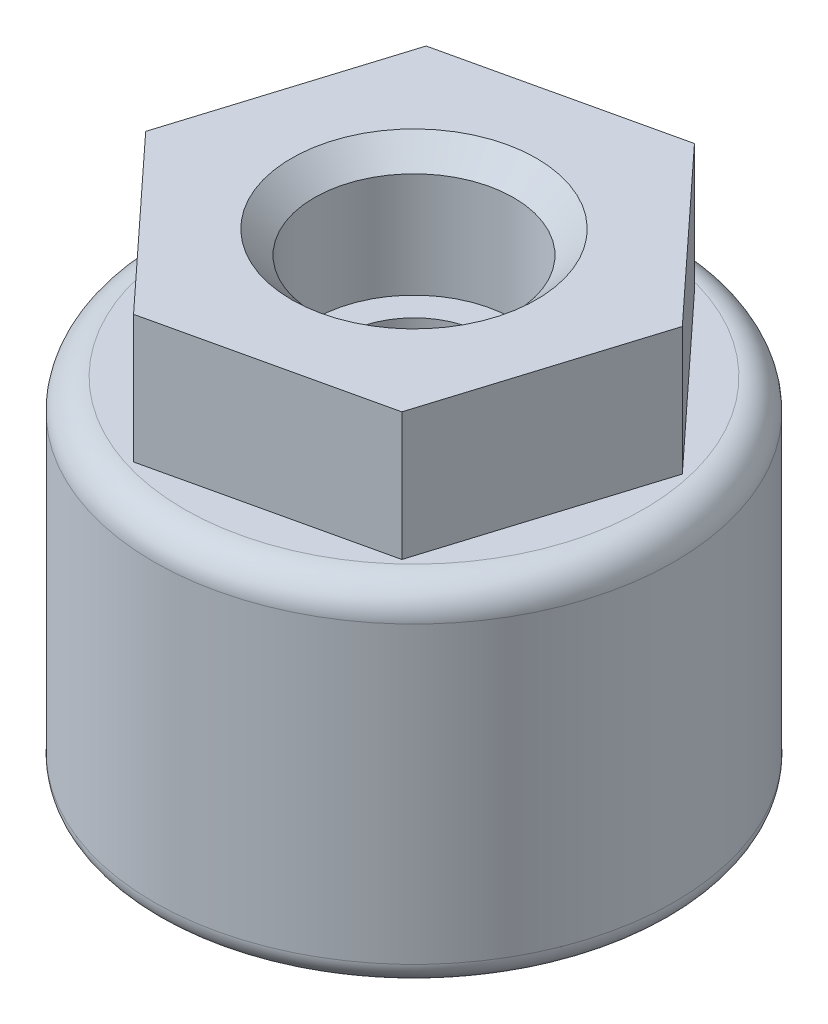
from build123d import *

# Parameters (mm, degrees)
SKETCH1_R               = 14.285
BOSS_EXTRUDE1_DEPTH     = 19.1
RADYUS1_R               = 1.67
RADYUS2_R               = 1.25
BOSS_EXTRUDE2_DEPTH     = 7.02
SKETCH4_R               = 3.95
CUT_EXTRUDE1_DEPTH      = 2
CUT_EXTRUDE1_DEPTH_BACK = 29.02
SKETCH5_R               = 5.475
CUT_EXTRUDE2_DEPTH      = 7.02
PAH1_SIZE               = 1.25


with BuildPart() as part:
    # Sketch1 → Boss-Extrude1 (new body)
    with BuildSketch(Plane(origin=(0, 0, 0), x_dir=(1, 0, 0), z_dir=(0, 1, 0))):
        Circle(SKETCH1_R)
    extrude(amount=BOSS_EXTRUDE1_DEPTH)

    # Radyus1
    radyus1_edges = [part.edges().sort_by_distance(p)[0] for p in [
        (-14.285, 19.1, 0),
    ]]
    fillet(radyus1_edges, radius=RADYUS1_R)

    # Radyus2
    radyus2_edges = [part.edges().sort_by_distance(p)[0] for p in [
        (-14.285, 0, 0),
    ]]
    fillet(radyus2_edges, radius=RADYUS2_R)

    # Sketch2 → Boss-Extrude2 (add)
    with BuildSketch(Plane(origin=(0, 19.1, 0), x_dir=(1, 0, 0), z_dir=(0, 1, 0))):
        Polygon((8.364308265, -9.030641206), (12.002918829, 2.728382839), (3.638610564, 11.759024045), (-8.364308265, 9.030641206), (-12.002918829, -2.728382839), (-3.638610564, -11.759024045), align=None)
    extrude(amount=BOSS_EXTRUDE2_DEPTH)

    # Sketch4 → Cut-Extrude1 (cut, two sides)
    with BuildSketch(Plane(origin=(0, 26.12, 0), x_dir=(1, 0, 0), z_dir=(0, 1, 0))) as cut_extrude1_sk:
        Circle(SKETCH4_R)
    extrude(amount=CUT_EXTRUDE1_DEPTH, mode=Mode.SUBTRACT)
    extrude(cut_extrude1_sk.sketch, amount=-CUT_EXTRUDE1_DEPTH_BACK, mode=Mode.SUBTRACT)

    # Sketch5 → Cut-Extrude2 (cut)
    with BuildSketch(Plane(origin=(0, 26.12, 0), x_dir=(1, 0, 0), z_dir=(0, 1, 0))):
        Circle(SKETCH5_R)
    extrude(amount=-CUT_EXTRUDE2_DEPTH, mode=Mode.SUBTRACT)

    # Pah1
    pah1_edges = [part.edges().sort_by_distance(p)[0] for p in [
        (-5.475, 26.12, 0),
    ]]
    chamfer(pah1_edges, length=PAH1_SIZE)


solid = part.part
